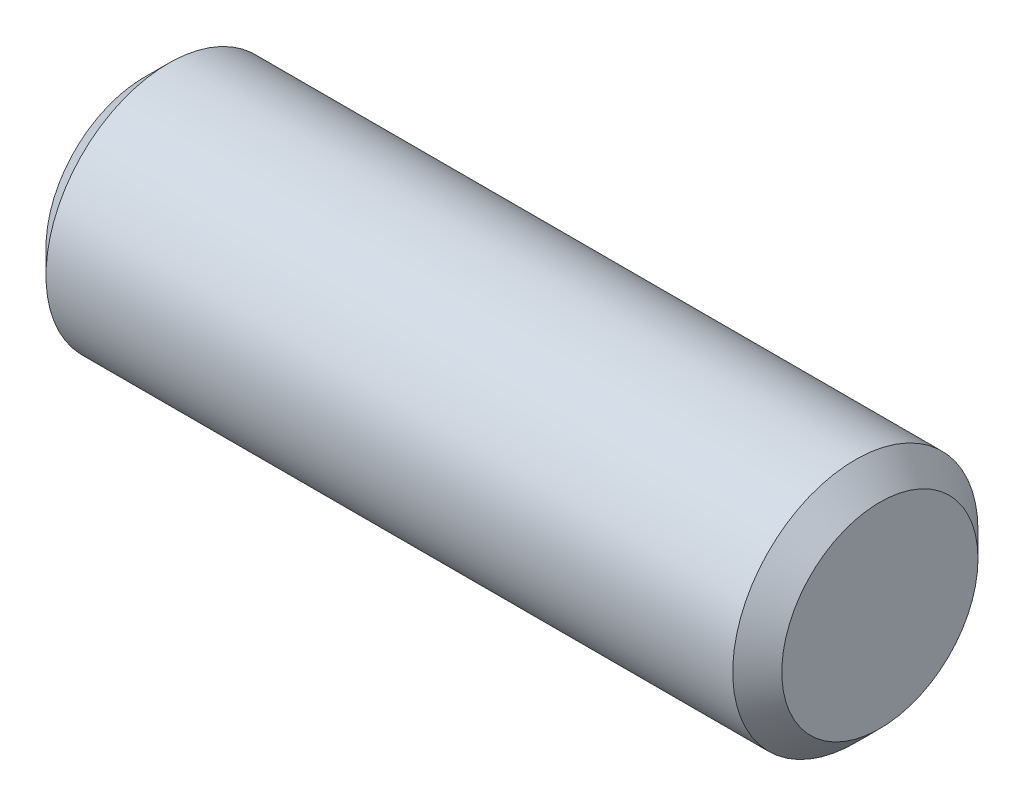
from build123d import *

# Parameters (mm, degrees)
SKETCH2_R           = 3.175
EXTRUDE1_DEPTH      = 9.525
EXTRUDE1_DEPTH_BACK = 9.525
CHAMFER1_SIZE       = 0.635


with BuildPart() as part:
    # Sketch2 → Extrude1 (new body, two sides)
    with BuildSketch(Plane(origin=(0, 0, 0), x_dir=(0, 0, -1), z_dir=(1, 0, 0))) as extrude1_sk:
        Circle(SKETCH2_R)
    extrude(amount=EXTRUDE1_DEPTH)
    extrude(extrude1_sk.sketch, amount=-EXTRUDE1_DEPTH_BACK)

    # Chamfer1
    chamfer1_edges = [part.edges().sort_by_distance(p)[0] for p in [
        (-9.525, 0, 3.175),
        (9.525, 0, 3.175),
    ]]
    chamfer(chamfer1_edges, length=CHAMFER1_SIZE)


solid = part.part
